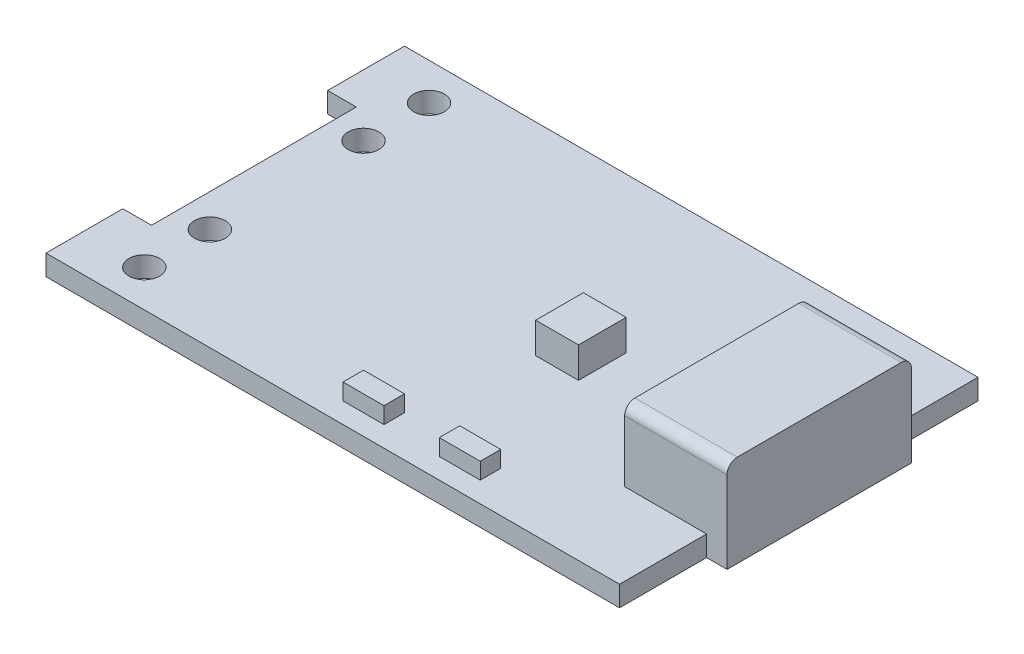
from build123d import *

# Parameters (mm, degrees)
SKETCH_1_W             = 28
SKETCH_1_H             = 17.5
EXTRUDE_1_DEPTH        = 1
EXTRUDE_START          = -1
SKETCH_2_W             = 5
SKETCH_2_H             = 9
EXTRUDE_2_DEPTH        = 4.5
FILLET_1_R             = 0.5
SKETCH_3_W             = 2.088904022
SKETCH_3_H             = 2.32763591
EXTRUDE_3_DEPTH        = 1.5
SKETCH_6_W             = 1.4
SKETCH_6_H             = 10
CUT_EXTRUDE_2_DEPTH    = 2
SKETCH_4_R             = 0.75
CUT_EXTRUDE_1_DEPTH    = 2
SKETCH_5_W             = 2
SKETCH_5_H             = 1
EXTRUDE_4_DEPTH        = 1.8
PATTERN_LINEAR_1_COUNT = 2
PATTERN_LINEAR_1_PITCH = 4.7


with BuildPart() as part:
    # 草图1 → 凸台-拉伸1 (new body)
    with BuildSketch(Plane(origin=(0, 0, 0), x_dir=(1, 0, 0), z_dir=(0, 1, 0))):
        Rectangle(SKETCH_1_W, SKETCH_1_H)
    extrude(amount=EXTRUDE_1_DEPTH)

    # 草图2 → 凸台-拉伸2 (add)
    with BuildSketch(Plane(origin=(0, 1, 0), x_dir=(1, 0, 0), z_dir=(0, 1, 0)).offset(EXTRUDE_START)):
        with Locations((12.5, 0)):
            Rectangle(SKETCH_2_W, SKETCH_2_H)
    extrude(amount=EXTRUDE_2_DEPTH)

    # 圆角1
    fillet_1_edges = [part.edges().sort_by_distance(p)[0] for p in [
        (12.5, 4.5, 4.5),
        (12.5, 4.5, -4.5),
    ]]
    fillet(fillet_1_edges, radius=FILLET_1_R)

    # 草图3 → 凸台-拉伸3 (add)
    with BuildSketch(Plane(origin=(0, 1, 0), x_dir=(1, 0, 0), z_dir=(0, 1, 0))):
        with Locations((3.334941172, 0.029841486)):
            Rectangle(SKETCH_3_W, SKETCH_3_H)
    extrude(amount=EXTRUDE_3_DEPTH)

    # 草图6 → 切除-拉伸2 (cut, through all)
    with BuildSketch(Plane(origin=(0, 1, 0), x_dir=(1, 0, 0), z_dir=(0, 1, 0))):
        with Locations((-13.3, 0)):
            Rectangle(SKETCH_6_W, SKETCH_6_H)
    extrude(amount=-CUT_EXTRUDE_2_DEPTH, mode=Mode.SUBTRACT)

    # 草图4 → 切除-拉伸1 (cut, through all)
    with BuildSketch(Plane(origin=(0, 1, 0), x_dir=(1, 0, 0), z_dir=(0, 1, 0))):
        with Locations((-11, 6.95)):
            Circle(SKETCH_4_R)
        with Locations((-11, 3.75)):
            Circle(SKETCH_4_R)
        with Locations((-11, -3.75)):
            Circle(SKETCH_4_R)
        with Locations((-11, -6.95)):
            Circle(SKETCH_4_R)
    extrude(amount=-CUT_EXTRUDE_1_DEPTH, mode=Mode.SUBTRACT)

    # 草图5 → 凸台-拉伸4 (add)
    with BuildSketch(Plane(origin=(0, 1, 0), x_dir=(1, 0, 0), z_dir=(0, 1, 0)).offset(EXTRUDE_START)):
        with Locations((5.2, -7.25)):
            Rectangle(SKETCH_5_W, SKETCH_5_H)
    extrude_4 = extrude(amount=EXTRUDE_4_DEPTH)

    # 阵列(线性)1: 凸台-拉伸4 ×2
    with Locations(*[(-i * PATTERN_LINEAR_1_PITCH, 0, 0) for i in range(1, PATTERN_LINEAR_1_COUNT)]):
        add(extrude_4)


solid = part.part
